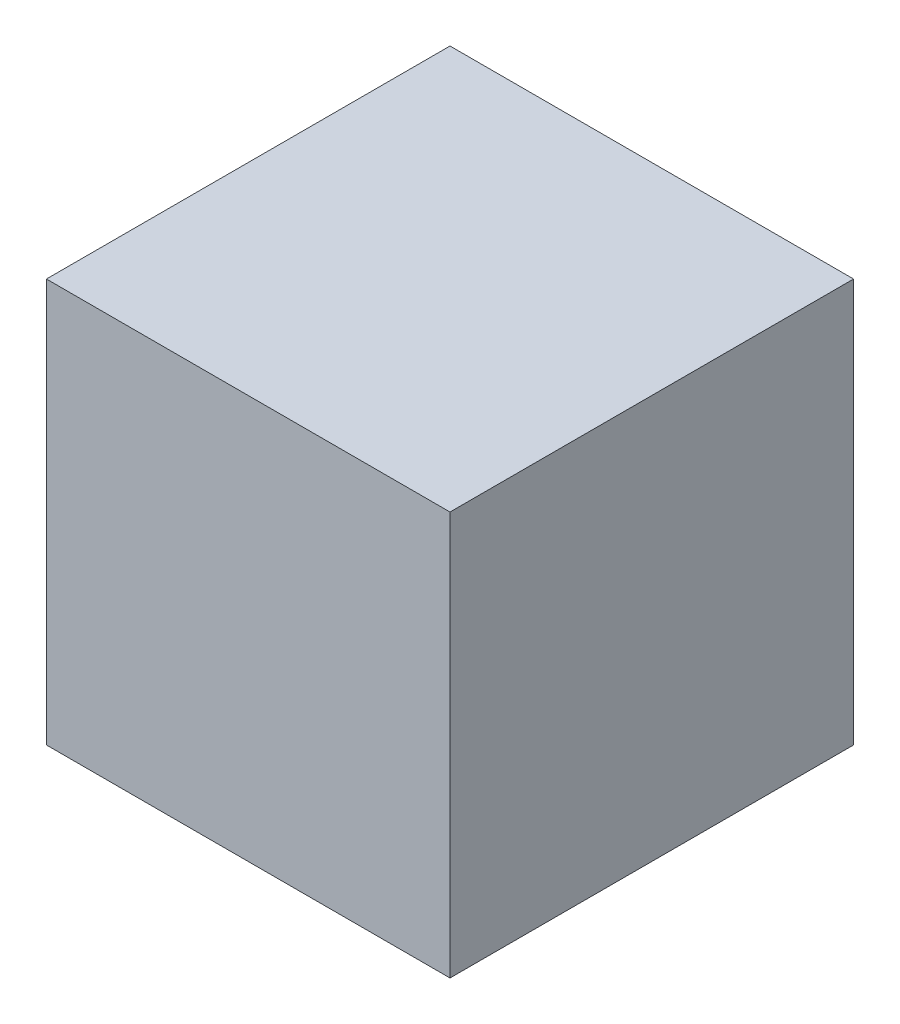
from build123d import *

# Parameters (mm, degrees)
ESQUISSE1_W        = 58
ESQUISSE1_H        = 58
BOSS_EXTRU_1_DEPTH = 58


with BuildPart() as part:
    # Esquisse1 → Boss.-Extru.1 (new body)
    with BuildSketch(Plane.XY):
        with Locations((29, 29)):
            Rectangle(ESQUISSE1_W, ESQUISSE1_H)
    extrude(amount=BOSS_EXTRU_1_DEPTH)


solid = part.part
